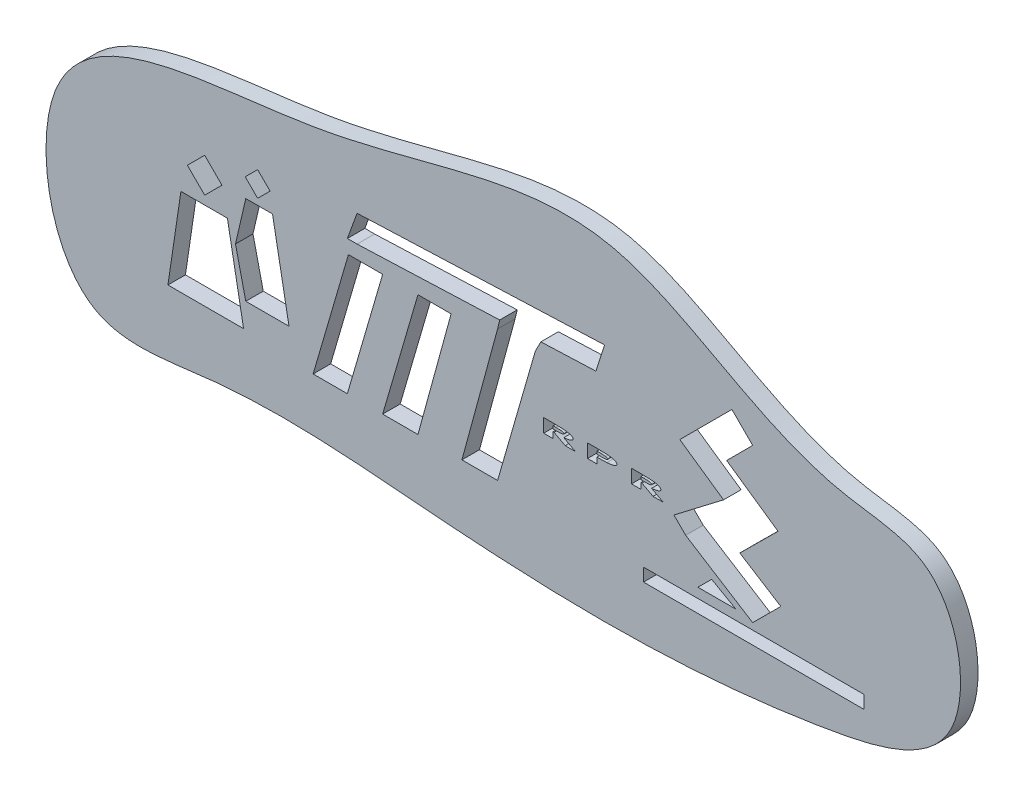
from build123d import *

# Parameters (mm, degrees)
BOSS_EXTRUDE2_DEPTH = 4.517429874
CUT_EXTRUDE4_DEPTH  = 25.4
CUT_EXTRUDE9_DEPTH  = 25.4
CUT_EXTRUDE11_DEPTH = 25.4
CUT_EXTRUDE12_DEPTH = 25.4
SKETCH13_W          = 56.880163442
SKETCH13_H          = 3.345891968
CUT_EXTRUDE13_DEPTH = 25.4
CUT_EXTRUDE14_DEPTH = 25.4
CUT_EXTRUDE15_DEPTH = 25.4
CUT_EXTRUDE16_DEPTH = 68.326
CUT_EXTRUDE26_DEPTH = 68.326
CUT_EXTRUDE27_DEPTH = 68.326
CUT_EXTRUDE32_DEPTH = 107.442


with BuildPart() as part:
    # Sketch2 → Boss-Extrude2 (new body)
    with BuildSketch(Plane.XY):
        with BuildLine():
            add(Edge.make_bspline(
                [(0, 0), (30.017953975, 5.069070708), (74.856056367, 26.760195969), (121.115195483, -14.831857803), (165.064468481, -15.192531708), (172.163248936, -60.148810443), (105.461448637, -75.125684233), (43.937664698, -72.90012531), (-16.643166707, -66.718259968), (-65.652567741, -76.76589293), (-77.848747515, -2.779333695), (-27.069286475, -4.571135237), (0, 0)],
                knots=[0, 0, 0, 0, 0.146698936, 0.264170019, 0.306774361, 0.367882044, 0.435987493, 0.626986044, 0.731787716, 0.784911513, 0.86771132, 1, 1, 1, 1], degree=3))
        make_face()
    extrude(amount=BOSS_EXTRUDE2_DEPTH)

    # Sketch5 → Cut-Extrude4 (cut)
    with BuildSketch(Plane.XY.offset(4.517429874)):
        Polygon((-37.457402706, -54.113470387), (-17.939699564, -54.113470387), (-22.122064523, -31.528699609), (-34.111510739, -31.528699609), align=None)
    extrude(amount=-CUT_EXTRUDE4_DEPTH, mode=Mode.SUBTRACT)

    # Sketch9 → Cut-Extrude9 (cut)
    with BuildSketch(Plane.XY.offset(4.517429874)):
        Polygon((-27.977375466, -29.317107242), (-32.438564755, -24.855917953), (-27.977375466, -20.394728663), (-23.516186176, -24.855917953), align=None)
    extrude(amount=-CUT_EXTRUDE9_DEPTH, mode=Mode.SUBTRACT)

    # Sketch10 → Cut-Extrude11 (cut)
    with BuildSketch(Plane.XY.offset(4.517429874)):
        Polygon((-17.382050903, -47.719513061), (-6.229077679, -47.719513061), (-10.479854444, -24.765318535), (-17.382050903, -24.765318535), (-20.030882044, -36.242415798), align=None)
    extrude(amount=-CUT_EXTRUDE11_DEPTH, mode=Mode.SUBTRACT)

    # Sketch12 → Cut-Extrude12 (cut)
    with BuildSketch(Plane.XY.offset(4.517429874)):
        Polygon((-14.314983267, -23.182971969), (-17.521463068, -19.976492167), (-14.314983267, -16.770012365), (-11.108503465, -19.976492167), align=None)
    extrude(amount=-CUT_EXTRUDE12_DEPTH, mode=Mode.SUBTRACT)

    # Sketch13 → Cut-Extrude13 (cut)
    with BuildSketch(Plane.XY.offset(4.517429874)):
        with Locations((113.665384476, -57.478364632)):
            Rectangle(SKETCH13_W, SKETCH13_H)
    extrude(amount=-CUT_EXTRUDE13_DEPTH, mode=Mode.SUBTRACT)

    # Sketch14 → Cut-Extrude14 (cut)
    with BuildSketch(Plane.XY.offset(4.517429874)):
        Polygon((113.386560145, -54.132472665), (120.635992741, -46.883040069), (110.06556228, -40.233898328), (119.926057908, -30.453725661), (106.665253444, -21.260724422), (113.386560145, -14.539417721), (108.02985233, -9.182709905), (94.587238927, -22.625323308), (105.879624316, -30.453725661), (93.075026205, -40.233898328), (96.099451649, -43.258323772), align=None)
    extrude(amount=-CUT_EXTRUDE14_DEPTH, mode=Mode.SUBTRACT)

    # Sketch15 → Cut-Extrude15 (cut)
    with BuildSketch(Plane.XY.offset(4.517429874)):
        Polygon((102.803326659, -49.738053832), (99.257603858, -53.283776633), (109.04379879, -53.283776633), align=None)
    extrude(amount=-CUT_EXTRUDE15_DEPTH, mode=Mode.SUBTRACT)

    # Sketch16 → Cut-Extrude16 (cut)
    with BuildSketch(Plane.XY.offset(4.517429874)):
        Polygon((11.336855148, -13.702944729), (75.187626854, -11.193525753), (72.957032209, -18.164134018), (11.336855148, -20.585887702), (8.827436173, -20.585887702), align=None)
    extrude(amount=-CUT_EXTRUDE16_DEPTH, mode=Mode.SUBTRACT)

    # Sketch17 → Cut-Extrude26 (cut)
    with BuildSketch(Plane.XY.offset(4.517429874)):
        Polygon((9.106260503, -24.041045158), (0, -55.269370185), (8.827436173, -55.269370185), (17.933696676, -24.041045158), align=None)
        Polygon((17.933696676, -55.269370185), (27.039957179, -24.041045158), (35.59457191, -24.041045158), (27.039957179, -55.269370185), align=None)
        Polygon((47.584018125, -21.419632419), (57.342869696, -21.419632419), (47.584018125, -55.269370185), (38.382815216, -55.269370185), align=None)
    extrude(amount=-CUT_EXTRUDE26_DEPTH, mode=Mode.SUBTRACT)

    # Sketch21 → Cut-Extrude27 (cut)
    with BuildSketch(Plane.XY.offset(4.517429874)):
        Polygon((48.125231005, -19.140056336), (58.737039127, -18.722998375), (57.342869696, -21.419632419), (47.584018125, -21.419632419), align=None)
    extrude(amount=-CUT_EXTRUDE27_DEPTH, mode=Mode.SUBTRACT)

    # Sketch24 → Cut-Extrude32 (cut)
    with BuildSketch(Plane.XY.offset(4.517429874)):
        with BuildLine():
            Line((59.47292796, -35.265571534), (62.049550556, -35.265571534))
            add(Edge.make_bspline(
                [(62.049550556, -35.265571534), (62.136255777, -35.265836753), (62.306394347, -35.266357183), (62.556700093, -35.266587307), (62.797417514, -35.26897806), (63.028790357, -35.271666475), (63.250577977, -35.275258065), (63.463035248, -35.279104561), (63.665634984, -35.285243975), (63.858945153, -35.290283366), (64.042626085, -35.297585529), (64.216979859, -35.305170329), (64.381748884, -35.31357176), (64.53670486, -35.322634484), (64.682310287, -35.33246229), (64.8183387, -35.342905467), (64.94507176, -35.353844617), (65.099120143, -35.37080664), (65.280705519, -35.393158594), (65.488811302, -35.424572197), (65.686155011, -35.460301286), (65.872380242, -35.499897142), (66.047531246, -35.544173586), (66.211612398, -35.592226824), (66.364843034, -35.644887296), (66.506460431, -35.700893258), (66.634028142, -35.760477), (66.746088551, -35.822473965), (66.840398956, -35.888466426), (66.918866991, -35.956154427), (66.979869525, -36.027676197), (67.02338595, -36.10210357), (67.051669225, -36.179722253), (67.054732966, -36.233123407), (67.056261294, -36.259762239)],
                knots=[0, 0, 0, 0, 0.000260117, 0.000510419, 0.000750913, 0.0009823, 0.001204583, 0.001416364, 0.001619766, 0.001812656, 0.001996484, 0.002171234, 0.002336212, 0.002491428, 0.002636891, 0.002774014, 0.002900714, 0.003018479, 0.003238931, 0.003449541, 0.003649775, 0.003840507, 0.004020588, 0.004191634, 0.004353271, 0.004506511, 0.004648278, 0.004775421, 0.004890182, 0.004993009, 0.005085562, 0.005170701, 0.005250743, 0.005330415, 0.005330415, 0.005330415, 0.005330415], degree=3))
            add(Edge.make_bspline(
                [(67.056261294, -36.259762239), (67.054566622, -36.287582081), (67.051160765, -36.343492858), (67.020988583, -36.424685808), (66.972700972, -36.501312469), (66.905697627, -36.574412484), (66.820178171, -36.643187382), (66.716147048, -36.708572086), (66.594058712, -36.770545369), (66.452776051, -36.828122066), (66.293557138, -36.883667855), (66.114856254, -36.93393353), (65.917884944, -36.982626066), (65.70131757, -37.026039081), (65.466170742, -37.06738865), (65.211784683, -37.105031005), (64.938742329, -37.139353575), (64.750081973, -37.158529631), (64.652815781, -37.168416085)],
                knots=[0, 0, 0, 0, 8.3233e-05, 0.000167277, 0.000256386, 0.000353683, 0.000463295, 0.000584662, 0.00072169, 0.00087351, 0.001042027, 0.001227321, 0.001430189, 0.001650606, 0.001889787, 0.002146402, 0.002421989, 0.002715282, 0.002715282, 0.002715282, 0.002715282], degree=3))
            Line((64.652815781, -37.168416085), (67.662030524, -38.765571534))
            Line((67.662030524, -38.765571534), (65.038432768, -38.765571534))
            Line((65.038432768, -38.765571534), (62.164534531, -37.239930508))
            Line((62.164534531, -37.239930508), (61.896004883, -37.239930508))
            Line((61.896004883, -37.239930508), (61.896004883, -38.765571534))
            Line((61.896004883, -38.765571534), (59.47292796, -38.765571534))
            Line((59.47292796, -38.765571534), (59.47292796, -35.265571534))
        make_face()
        with BuildLine():
            Line((61.896004883, -36.61172538), (62.666537736, -36.61172538))
            add(Edge.make_bspline(
                [(62.666537736, -36.61172538), (62.714448383, -36.611859013), (62.808402367, -36.61212107), (62.946285263, -36.610242964), (63.078567189, -36.609052202), (63.205020597, -36.607255123), (63.325824807, -36.603264684), (63.441060318, -36.60006876), (63.550670828, -36.595810637), (63.654451025, -36.591063998), (63.752339215, -36.585062005), (63.844498147, -36.580081567), (63.931168112, -36.5726872), (64.012072738, -36.565300003), (64.08725852, -36.556481411), (64.156827589, -36.548712484), (64.220507837, -36.538409749), (64.296093993, -36.526127377), (64.380428469, -36.507932552), (64.470734994, -36.482247207), (64.547448004, -36.45355167), (64.610357823, -36.420590954), (64.659944003, -36.384139248), (64.69635144, -36.344126238), (64.718856728, -36.298981482), (64.721569549, -36.267241953), (64.72292796, -36.251348777)],
                knots=[0, 0, 0, 0, 0.00014373, 0.000281858, 0.000413676, 0.000540597, 0.000661241, 0.000776278, 0.000886435, 0.000990317, 0.001087934, 0.001180652, 0.001267174, 0.001348869, 0.00142436, 0.001494279, 0.001558831, 0.001617847, 0.00172401, 0.001817428, 0.001899327, 0.001969275, 0.002029852, 0.002083012, 0.002130368, 0.002177863, 0.002177863, 0.002177863, 0.002177863], degree=3))
            add(Edge.make_bspline(
                [(64.72292796, -36.251348777), (64.722163283, -36.241935304), (64.720612581, -36.222845552), (64.710510578, -36.194571626), (64.691677049, -36.168646917), (64.668226189, -36.142233124), (64.636116063, -36.11900337), (64.599040165, -36.094464897), (64.553839199, -36.072872942), (64.483163978, -36.042655591), (64.380730455, -36.009943422), (64.243000769, -35.976424617), (64.086457228, -35.949799769), (63.941918031, -35.93241264), (63.809436885, -35.921778977), (63.688842746, -35.913984878), (63.549273505, -35.908120044), (63.390594774, -35.902297015), (63.212492929, -35.898304042), (63.015237302, -35.895522742), (62.798817364, -35.894337822), (62.648308609, -35.893969058), (62.569782928, -35.893776662)],
                knots=[0, 0, 0, 0, 2.8263e-05, 5.7315e-05, 8.8623e-05, 0.000123854, 0.000162841, 0.000206989, 0.000257157, 0.000312763, 0.000437588, 0.000579069, 0.000737792, 0.000913634, 0.001015644, 0.001136484, 0.001276149, 0.001434702, 0.001612837, 0.001810573, 0.002026523, 0.002262101, 0.002262101, 0.002262101, 0.002262101], degree=3))
            Line((62.569782928, -35.893776662), (61.896004883, -35.893776662))
            Line((61.896004883, -35.893776662), (61.896004883, -36.61172538))
        make_face(mode=Mode.SUBTRACT)
        with BuildLine():
            Line((70.776133088, -35.265571534), (73.352755685, -35.265571534))
            add(Edge.make_bspline(
                [(73.352755685, -35.265571534), (73.438292385, -35.2658361), (73.606561325, -35.266356558), (73.854296095, -35.266595344), (74.092911032, -35.268947417), (74.322411073, -35.271775267), (74.54281227, -35.274897873), (74.754062359, -35.280379016), (74.956248037, -35.284709342), (75.149280446, -35.291282665), (75.333213103, -35.298210728), (75.508031196, -35.305909124), (75.673730284, -35.314346726), (75.830361907, -35.32308112), (75.977532563, -35.334134186), (76.115973864, -35.344093655), (76.245194272, -35.356170392), (76.403538823, -35.372723042), (76.589449843, -35.396191481), (76.802407124, -35.426951129), (77.002742555, -35.464177268), (77.191602193, -35.502319398), (77.367708023, -35.54704793), (77.531942289, -35.594079637), (77.683784989, -35.646080091), (77.822868406, -35.701387366), (77.947379306, -35.760805117), (78.057012907, -35.821781739), (78.149542125, -35.886990701), (78.225679352, -35.955018015), (78.285301049, -36.026293822), (78.327630089, -36.101282432), (78.354547163, -36.17943636), (78.357836735, -36.233151316), (78.359466422, -36.259762239)],
                knots=[0, 0, 0, 0, 0.000256612, 0.00050481, 0.0007432, 0.000972484, 0.001193365, 0.00140446, 0.001606443, 0.001800055, 0.001983883, 0.002158633, 0.002325011, 0.002481627, 0.002629238, 0.002767758, 0.002898013, 0.003018567, 0.003245367, 0.003460137, 0.003663946, 0.003856591, 0.004038031, 0.004208881, 0.004368964, 0.004519339, 0.004657638, 0.004782605, 0.004895244, 0.004996502, 0.005088159, 0.005172602, 0.005253751, 0.005333423, 0.005333423, 0.005333423, 0.005333423], degree=3))
            add(Edge.make_bspline(
                [(78.359466422, -36.259762239), (78.358946302, -36.274531176), (78.357905866, -36.304074609), (78.348841807, -36.34774526), (78.335850734, -36.390762562), (78.316406023, -36.432522088), (78.291867158, -36.473289743), (78.261248847, -36.512785557), (78.225227709, -36.551089736), (78.184605454, -36.589580018), (78.136945588, -36.62525824), (78.085654703, -36.662406014), (78.027338068, -36.695940104), (77.965106387, -36.731118759), (77.896257665, -36.763271079), (77.822651712, -36.795961984), (77.743141314, -36.826503362), (77.628094444, -36.867305438), (77.473367764, -36.916039165), (77.2748845, -36.968243595), (77.060769272, -37.015555032), (76.831150528, -37.058966274), (76.5858516, -37.097923688), (76.324984452, -37.132948328), (76.048659826, -37.163169218), (75.859073996, -37.178685093), (75.761810172, -37.186645252)],
                knots=[0, 0, 0, 0, 4.426e-05, 8.8536e-05, 0.000133331, 0.000178823, 0.000226318, 0.000275821, 0.00032841, 0.000383971, 0.000443434, 0.000506846, 0.000573821, 0.000645053, 0.000721256, 0.000801628, 0.000886649, 0.000976683, 0.001167826, 0.001373093, 0.001592185, 0.001825537, 0.00207405, 0.002337213, 0.002615095, 0.002907852, 0.002907852, 0.002907852, 0.002907852], degree=3))
            add(Edge.make_bspline(
                [(75.761810172, -37.186645252), (75.730962902, -37.188779235), (75.666243803, -37.193256436), (75.564829435, -37.199635897), (75.454278906, -37.205258253), (75.334829631, -37.209846057), (75.206309302, -37.21507402), (75.068868733, -37.218927444), (74.922347605, -37.223396166), (74.766693126, -37.226827198), (74.60192182, -37.22947074), (74.428043077, -37.232206208), (74.245294035, -37.235467912), (74.053642707, -37.236347249), (73.852889636, -37.23785848), (73.643022167, -37.239395154), (73.424036841, -37.240073146), (73.275164895, -37.239978696), (73.199210011, -37.239930508)],
                knots=[0, 0, 0, 0, 9.2763e-05, 0.000194621, 0.00030484, 0.000424832, 0.000553232, 0.000690716, 0.000837311, 0.000992999, 0.001157787, 0.001331687, 0.001514702, 0.001706113, 0.001906639, 0.00211698, 0.002335731, 0.002563596, 0.002563596, 0.002563596, 0.002563596], degree=3))
            Line((73.199210011, -37.239930508), (73.199210011, -38.765571534))
            Line((73.199210011, -38.765571534), (70.776133088, -38.765571534))
            Line((70.776133088, -38.765571534), (70.776133088, -35.265571534))
        make_face()
        with BuildLine():
            Line((73.199210011, -36.61172538), (73.978156326, -36.61172538))
            add(Edge.make_bspline(
                [(73.978156326, -36.61172538), (74.05177426, -36.6115344), (74.193402406, -36.611166989), (74.396967519, -36.609956993), (74.583010296, -36.607288697), (74.751272927, -36.602867714), (74.902280092, -36.598370479), (75.035718823, -36.591877535), (75.151700103, -36.585309213), (75.279709622, -36.574354251), (75.419561208, -36.557113668), (75.570641939, -36.530970288), (75.702740584, -36.499335391), (75.800045037, -36.467235364), (75.867143777, -36.438496578), (75.9091755, -36.416275299), (75.944922877, -36.392869336), (75.974479842, -36.368759136), (75.997625926, -36.343085494), (76.014222935, -36.316369347), (76.023805753, -36.287960605), (76.025356093, -36.268709397), (76.026133088, -36.259061117)],
                knots=[0, 0, 0, 0, 0.000220854, 0.000424886, 0.000610704, 0.000779026, 0.000929847, 0.00106391, 0.001179807, 0.001278324, 0.001449294, 0.001602372, 0.001738071, 0.001856467, 0.00190922, 0.001956896, 0.001998899, 0.00203723, 0.002071001, 0.002102144, 0.002130966, 0.002159925, 0.002159925, 0.002159925, 0.002159925], degree=3))
            add(Edge.make_bspline(
                [(76.026133088, -36.259061117), (76.024266485, -36.242348967), (76.020425896, -36.207963243), (75.990401482, -36.159996507), (75.942619857, -36.118366757), (75.878434754, -36.078975246), (75.79605891, -36.044926584), (75.696226664, -36.013767934), (75.578714578, -35.985082815), (75.493628163, -35.970785873), (75.448408729, -35.96318772)],
                knots=[0, 0, 0, 0, 4.9918e-05, 0.000102707, 0.000164728, 0.000239047, 0.00032761, 0.000431381, 0.000552626, 0.00069015, 0.00069015, 0.00069015, 0.00069015], degree=3))
            add(Edge.make_bspline(
                [(75.448408729, -35.96318772), (75.429961586, -35.96026963), (75.391269719, -35.954149098), (75.330173552, -35.946890921), (75.263895704, -35.938685727), (75.191803917, -35.932947162), (75.114259439, -35.926267715), (75.030774848, -35.921107238), (74.941788046, -35.9149298), (74.847076503, -35.911349765), (74.746840455, -35.906802921), (74.640962436, -35.903374976), (74.529705259, -35.90079029), (74.412861303, -35.897816017), (74.290398537, -35.895438263), (74.162079232, -35.89554972), (74.028174861, -35.893303471), (73.937024771, -35.893616792), (73.890516101, -35.893776662)],
                knots=[0, 0, 0, 0, 5.6024e-05, 0.000117507, 0.000184559, 0.000256351, 0.000334431, 0.000418053, 0.000507272, 0.000602017, 0.000702365, 0.000808293, 0.000919806, 0.001036226, 0.001158941, 0.001287248, 0.001421169, 0.001560693, 0.001560693, 0.001560693, 0.001560693], degree=3))
            Line((73.890516101, -35.893776662), (73.199210011, -35.893776662))
            Line((73.199210011, -35.893776662), (73.199210011, -36.61172538))
        make_face(mode=Mode.SUBTRACT)
        with BuildLine():
            Line((82.124210011, -35.265571534), (84.700832608, -35.265571534))
            add(Edge.make_bspline(
                [(84.700832608, -35.265571534), (84.787537828, -35.265836753), (84.957676398, -35.266357183), (85.207982145, -35.266587307), (85.448699566, -35.26897806), (85.680072409, -35.271666475), (85.901860029, -35.275258065), (86.114317299, -35.279104561), (86.316917035, -35.285243975), (86.510227204, -35.290283366), (86.693908137, -35.297585529), (86.868261911, -35.305170329), (87.033030935, -35.31357176), (87.187986911, -35.322634484), (87.333592338, -35.33246229), (87.469620752, -35.342905467), (87.596353811, -35.353844617), (87.750402195, -35.37080664), (87.931987571, -35.393158594), (88.140093353, -35.424572197), (88.337437063, -35.460301286), (88.523662293, -35.499897142), (88.698813297, -35.544173586), (88.862894449, -35.592226824), (89.016125085, -35.644887296), (89.157742482, -35.700893258), (89.285310194, -35.760477), (89.397370603, -35.822473965), (89.491681008, -35.888466426), (89.570149042, -35.956154427), (89.631151577, -36.027676197), (89.674668001, -36.10210357), (89.702951276, -36.179722253), (89.706015017, -36.233123407), (89.707543345, -36.259762239)],
                knots=[0, 0, 0, 0, 0.000260117, 0.000510419, 0.000750913, 0.0009823, 0.001204583, 0.001416364, 0.001619766, 0.001812656, 0.001996484, 0.002171234, 0.002336212, 0.002491428, 0.002636891, 0.002774014, 0.002900714, 0.003018479, 0.003238931, 0.003449541, 0.003649775, 0.003840507, 0.004020588, 0.004191634, 0.004353271, 0.004506511, 0.004648278, 0.004775421, 0.004890182, 0.004993009, 0.005085562, 0.005170701, 0.005250743, 0.005330415, 0.005330415, 0.005330415, 0.005330415], degree=3))
            add(Edge.make_bspline(
                [(89.707543345, -36.259762239), (89.705848673, -36.287582081), (89.702442816, -36.343492858), (89.672270634, -36.424685808), (89.623983023, -36.501312469), (89.556979678, -36.574412484), (89.471460222, -36.643187382), (89.367429099, -36.708572086), (89.245340763, -36.770545369), (89.104058103, -36.828122066), (88.944839189, -36.883667855), (88.766138305, -36.93393353), (88.569166996, -36.982626066), (88.352599621, -37.026039081), (88.117452793, -37.06738865), (87.863066734, -37.105031005), (87.59002438, -37.139353575), (87.401364024, -37.158529631), (87.304097832, -37.168416085)],
                knots=[0, 0, 0, 0, 8.3233e-05, 0.000167277, 0.000256386, 0.000353683, 0.000463295, 0.000584662, 0.00072169, 0.00087351, 0.001042027, 0.001227321, 0.001430189, 0.001650606, 0.001889787, 0.002146402, 0.002421989, 0.002715282, 0.002715282, 0.002715282, 0.002715282], degree=3))
            Line((87.304097832, -37.168416085), (90.313312576, -38.765571534))
            Line((90.313312576, -38.765571534), (87.689714819, -38.765571534))
            Line((87.689714819, -38.765571534), (84.815816582, -37.239930508))
            Line((84.815816582, -37.239930508), (84.547286935, -37.239930508))
            Line((84.547286935, -37.239930508), (84.547286935, -38.765571534))
            Line((84.547286935, -38.765571534), (82.124210011, -38.765571534))
            Line((82.124210011, -38.765571534), (82.124210011, -35.265571534))
        make_face()
        with BuildLine():
            Line((84.547286935, -36.61172538), (85.317819787, -36.61172538))
            add(Edge.make_bspline(
                [(85.317819787, -36.61172538), (85.365730435, -36.611859013), (85.459684418, -36.61212107), (85.597567314, -36.610242964), (85.72984924, -36.609052202), (85.856302648, -36.607255123), (85.977106858, -36.603264684), (86.09234237, -36.60006876), (86.201952879, -36.595810637), (86.305733076, -36.591063998), (86.403621267, -36.585062005), (86.495780199, -36.580081567), (86.582450163, -36.5726872), (86.66335479, -36.565300003), (86.738540571, -36.556481411), (86.808109641, -36.548712484), (86.871789889, -36.538409749), (86.947376044, -36.526127377), (87.03171052, -36.507932552), (87.122017045, -36.482247207), (87.198730055, -36.45355167), (87.261639874, -36.420590954), (87.311226054, -36.384139248), (87.347633491, -36.344126238), (87.370138779, -36.298981482), (87.3728516, -36.267241953), (87.374210011, -36.251348777)],
                knots=[0, 0, 0, 0, 0.00014373, 0.000281858, 0.000413676, 0.000540597, 0.000661241, 0.000776278, 0.000886435, 0.000990317, 0.001087934, 0.001180652, 0.001267174, 0.001348869, 0.00142436, 0.001494279, 0.001558831, 0.001617847, 0.00172401, 0.001817428, 0.001899327, 0.001969275, 0.002029852, 0.002083012, 0.002130368, 0.002177863, 0.002177863, 0.002177863, 0.002177863], degree=3))
            add(Edge.make_bspline(
                [(87.374210011, -36.251348777), (87.373445335, -36.241935304), (87.371894633, -36.222845552), (87.361792629, -36.194571626), (87.3429591, -36.168646917), (87.319508241, -36.142233124), (87.287398114, -36.11900337), (87.250322216, -36.094464897), (87.20512125, -36.072872942), (87.13444603, -36.042655591), (87.032012506, -36.009943422), (86.89428282, -35.976424617), (86.737739279, -35.949799769), (86.593200083, -35.93241264), (86.460718936, -35.921778977), (86.340124797, -35.913984878), (86.200555556, -35.908120044), (86.041876825, -35.902297015), (85.86377498, -35.898304042), (85.666519353, -35.895522742), (85.450099415, -35.894337822), (85.299590661, -35.893969058), (85.221064979, -35.893776662)],
                knots=[0, 0, 0, 0, 2.8263e-05, 5.7315e-05, 8.8623e-05, 0.000123854, 0.000162841, 0.000206989, 0.000257157, 0.000312763, 0.000437588, 0.000579069, 0.000737792, 0.000913634, 0.001015644, 0.001136484, 0.001276149, 0.001434702, 0.001612837, 0.001810573, 0.002026523, 0.002262101, 0.002262101, 0.002262101, 0.002262101], degree=3))
            Line((85.221064979, -35.893776662), (84.547286935, -35.893776662))
            Line((84.547286935, -35.893776662), (84.547286935, -36.61172538))
        make_face(mode=Mode.SUBTRACT)
    extrude(amount=-CUT_EXTRUDE32_DEPTH, mode=Mode.SUBTRACT)


solid = part.part
